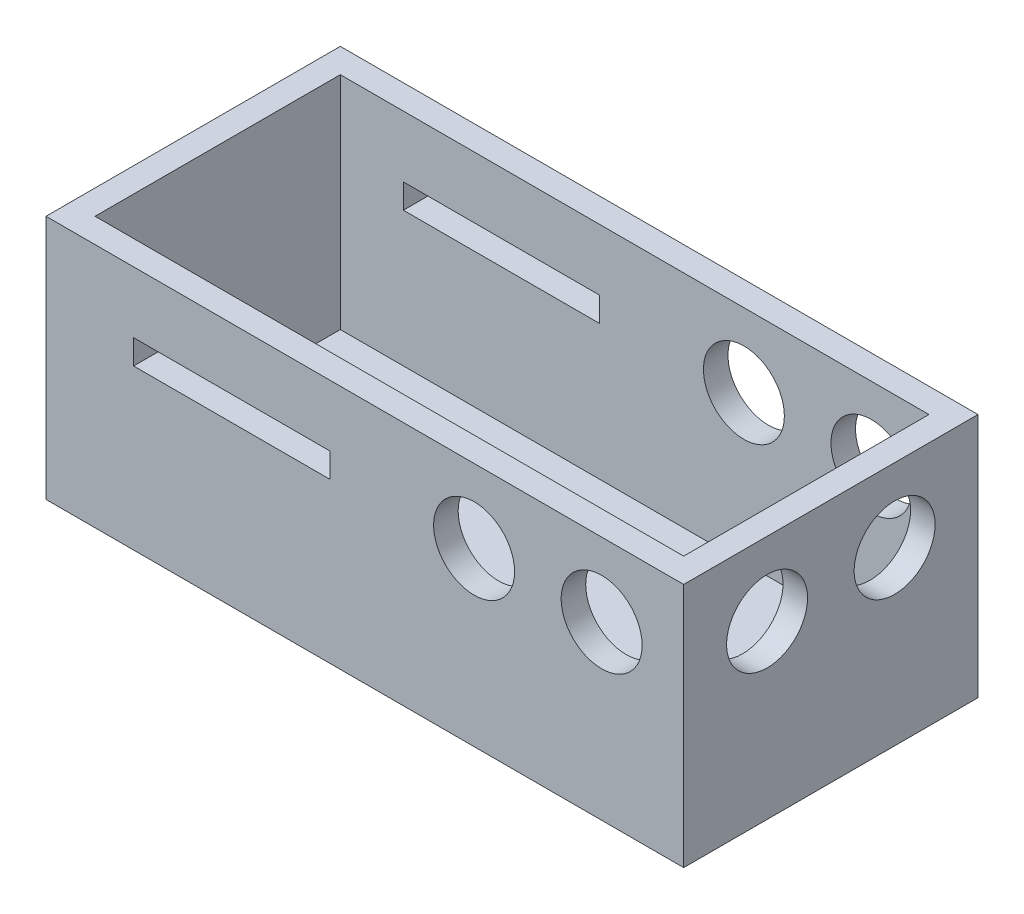
from build123d import *

# Parameters (mm, degrees)
SKETCH1_W           = 130
SKETCH1_H           = 60
BOSS_EXTRUDE2_DEPTH = 50
SHELL1_T            = -5
CUT_EXTRUDE1_REACH  = 132
SKETCH2_R           = 8.25
SKETCH3_R           = 8.25
CUT_EXTRUDE2_DEPTH  = 61
SKETCH4_W           = 40
SKETCH4_H           = 5
CUT_EXTRUDE3_DEPTH  = 61


with BuildPart() as part:
    # Sketch1 → Boss-Extrude2 (new body)
    with BuildSketch(Plane(origin=(0, 0, 0), x_dir=(1, 0, 0), z_dir=(0, 1, 0))):
        Rectangle(SKETCH1_W, SKETCH1_H)
    extrude(amount=BOSS_EXTRUDE2_DEPTH)

    # Shell1
    shell1_openings = [part.faces().sort_by_distance(p)[0] for p in [
        (0, 50, 0),
    ]]
    offset(amount=SHELL1_T, openings=shell1_openings, kind=Kind.INTERSECTION)

    # Sketch2 → Cut-Extrude1 (cut, up to next)
    with BuildSketch(Plane(origin=(65, 0, 0), x_dir=(0, 0, -1), z_dir=(1, 0, 0)), mode=Mode.PRIVATE) as cut_extrude1_sk1:
        with Locations((-13, 35)):
            Circle(SKETCH2_R)
    cut_extrude1_tool1 = extrude(cut_extrude1_sk1.sketch, amount=-CUT_EXTRUDE1_REACH, mode=Mode.PRIVATE) & part.part
    add(cut_extrude1_tool1.solids().sort_by_distance((65, 35, 13))[0], mode=Mode.SUBTRACT)
    # Sketch2 → Cut-Extrude1 (cut, up to next)
    with BuildSketch(Plane(origin=(65, 0, 0), x_dir=(0, 0, -1), z_dir=(1, 0, 0)), mode=Mode.PRIVATE) as cut_extrude1_sk2:
        with BuildLine():
            ThreePointArc((21.25, 35), (13, 43.25), (4.75, 35))
            ThreePointArc((4.75, 35), (13, 26.75), (21.25, 35))
        make_face()
    cut_extrude1_tool2 = extrude(cut_extrude1_sk2.sketch, amount=-CUT_EXTRUDE1_REACH, mode=Mode.PRIVATE) & part.part
    add(cut_extrude1_tool2.solids().sort_by_distance((65, 35, -13))[0], mode=Mode.SUBTRACT)

    # Sketch3 → Cut-Extrude2 (cut, through all)
    with BuildSketch(Plane.XY.offset(30)):
        with Locations((22.274243645, 35)):
            Circle(SKETCH3_R)
        with Locations((48.274243645, 35)):
            Circle(SKETCH3_R)
    extrude(amount=-CUT_EXTRUDE2_DEPTH, mode=Mode.SUBTRACT)

    # Sketch4 → Cut-Extrude3 (cut, through all)
    with BuildSketch(Plane(origin=(0, 0, -30), x_dir=(-1, 0, 0), z_dir=(0, 0, -1))):
        with Locations((27.140672083, 35)):
            Rectangle(SKETCH4_W, SKETCH4_H)
    extrude(amount=-CUT_EXTRUDE3_DEPTH, mode=Mode.SUBTRACT)


solid = part.part
